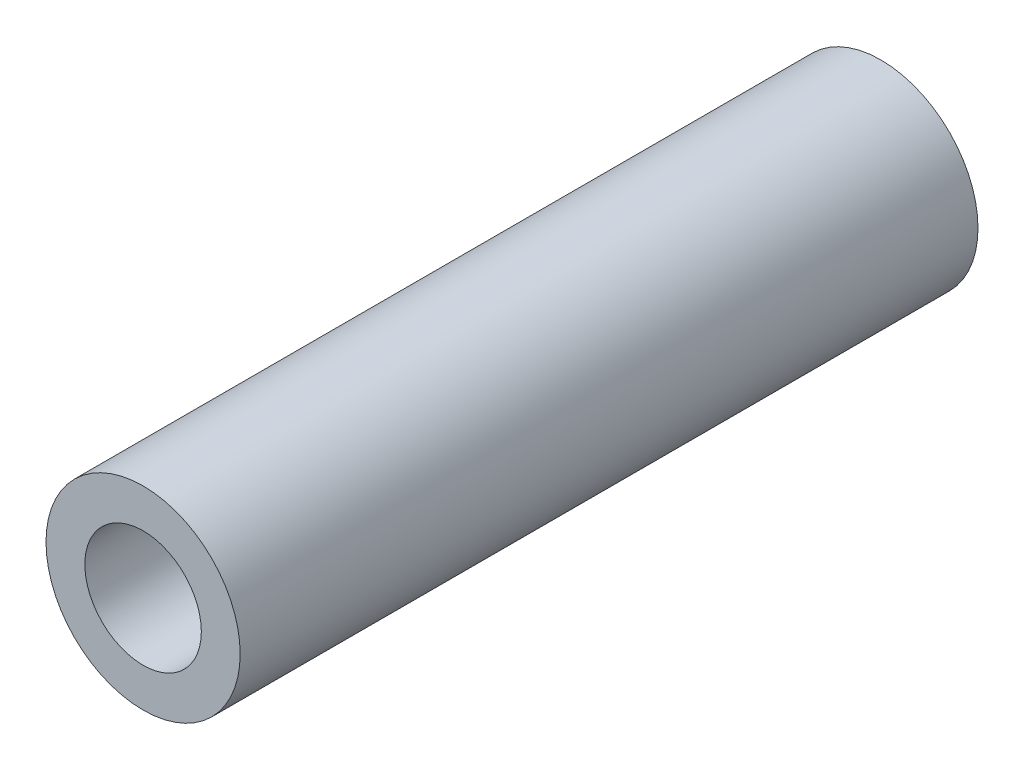
from build123d import *

# Parameters (mm, degrees)
ESBO_O1_R                = 5
ESBO_O1_R_2              = 3
RESSALTO_EXTRUS_O1_DEPTH = 38


with BuildPart() as part:
    # Esboço1 → Ressalto-extrusão1 (new body)
    with BuildSketch(Plane.XY):
        Circle(ESBO_O1_R)
        Circle(ESBO_O1_R_2, mode=Mode.SUBTRACT)
    extrude(amount=RESSALTO_EXTRUS_O1_DEPTH)


solid = part.part
